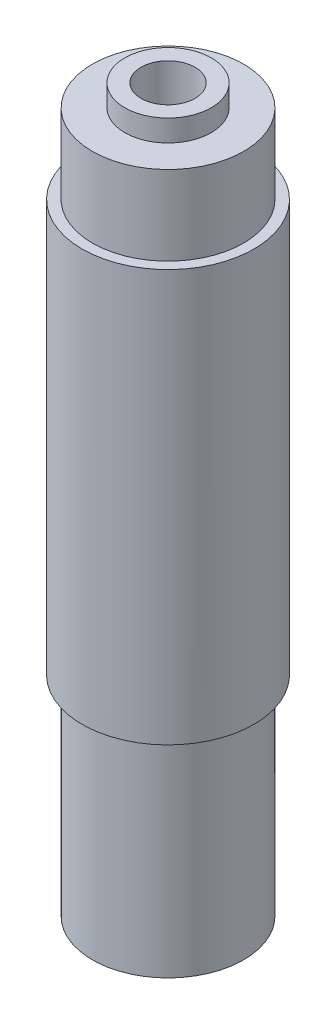
from build123d import *

# Parameters (mm, degrees)
SKETCH2_R             = 3.9751
BOSS_EXTRUDE1_DEPTH   = 17.2
M3X0_5_TAPPED_HOLE1_D = 2.5
SKETCH5_R             = 3.9751
SKETCH5_R_2           = 3.5
CUT_EXTRUDE1_DEPTH    = 4.675
SKETCH6_R             = 3.5
SKETCH6_R_2           = 2
CUT_EXTRUDE2_DEPTH    = 1
SKETCH7_R             = 3.9751
SKETCH7_R_2           = 3.5
CUT_EXTRUDE3_DEPTH    = 10.675
SKETCH8_R             = 3.5
SKETCH8_R_2           = 2
CUT_EXTRUDE4_DEPTH    = 1


with BuildPart() as part:
    # Sketch2 → Boss-Extrude1 (new body, symmetric)
    with BuildSketch(Plane(origin=(0, 0, 0), x_dir=(1, 0, 0), z_dir=(0, 1, 0))):
        Circle(SKETCH2_R)
    extrude(amount=BOSS_EXTRUDE1_DEPTH, both=True)

    # M3x0.5 Tapped Hole1 (through all)
    with Locations(Plane(origin=(0, 17.2, 0), x_dir=(1, 0, 0), z_dir=(0, 1, 0))):
        with Locations((0, 0)):
            Hole(M3X0_5_TAPPED_HOLE1_D / 2)

    # Sketch5 → Cut-Extrude1 (cut)
    with BuildSketch(Plane(origin=(0, 17.2, 0), x_dir=(1, 0, 0), z_dir=(0, 1, 0))):
        Circle(SKETCH5_R)
        Circle(SKETCH5_R_2, mode=Mode.SUBTRACT)
    extrude(amount=-CUT_EXTRUDE1_DEPTH, mode=Mode.SUBTRACT)

    # Sketch6 → Cut-Extrude2 (cut)
    with BuildSketch(Plane(origin=(0, 17.2, 0), x_dir=(1, 0, 0), z_dir=(0, 1, 0))):
        Circle(SKETCH6_R)
        Circle(SKETCH6_R_2, mode=Mode.SUBTRACT)
    extrude(amount=-CUT_EXTRUDE2_DEPTH, mode=Mode.SUBTRACT)

    # Sketch7 → Cut-Extrude3 (cut)
    with BuildSketch(Plane.XZ.offset(17.2)):
        Circle(SKETCH7_R)
        Circle(SKETCH7_R_2, mode=Mode.SUBTRACT)
    extrude(amount=-CUT_EXTRUDE3_DEPTH, mode=Mode.SUBTRACT)

    # Sketch8 → Cut-Extrude4 (cut)
    with BuildSketch(Plane.XZ.offset(17.2)):
        Circle(SKETCH8_R)
        Circle(SKETCH8_R_2, mode=Mode.SUBTRACT)
    extrude(amount=-CUT_EXTRUDE4_DEPTH, mode=Mode.SUBTRACT)


solid = part.part
